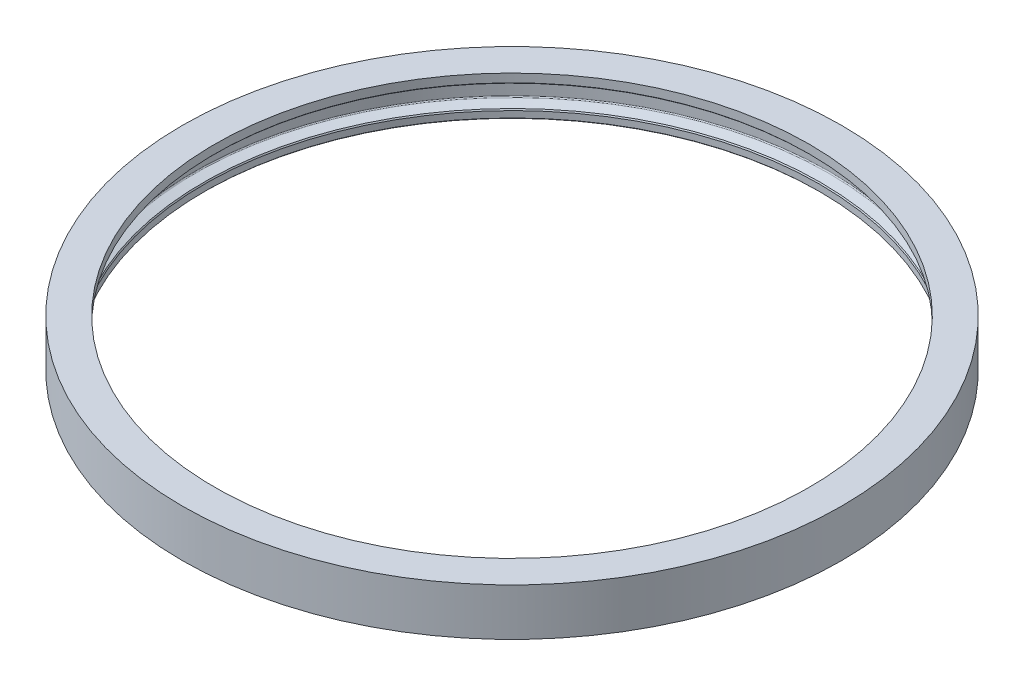
from build123d import *


with BuildPart() as part:
    # Sketch1 → Revolve3 (revolve)
    with BuildSketch(Plane(origin=(0, 0, 0), x_dir=(0, 0, -1), z_dir=(1, 0, 0))):
        with BuildLine():
            Line((8.255, 9.855919884), (8.001, 9.601919884))
            Line((8.001, 9.601919884), (3.3175, 9.601919884))
            ThreePointArc((3.3175, 9.601919884), (3.092993597, 9.508926287), (3, 9.284419884))
            Line((3, 9.284419884), (3, 3.324235778))
            ThreePointArc((3, 3.324235778), (3.057419226, 3.142125259), (3.208908604, 3.025883371))
            Line((3.208908604, 3.025883371), (5.441838421, 2.213163382))
            Line((5.441838421, 2.213163382), (5.6275, 1.891588094))
            Line((5.6275, 1.891588094), (5.6275, 0.254))
            Line((5.6275, 0.254), (5.3735, 0))
            Line((5.3735, 0), (0, 0))
            Line((0, 0), (0, 12.009719884))
            Line((0, 12.009719884), (8.255, 12.009719884))
            Line((8.255, 12.009719884), (8.255, 9.855919884))
        make_face()
    revolve(axis=Axis((0, 6.004859942, -83.82), (0, 1, 0)))


solid = part.part
